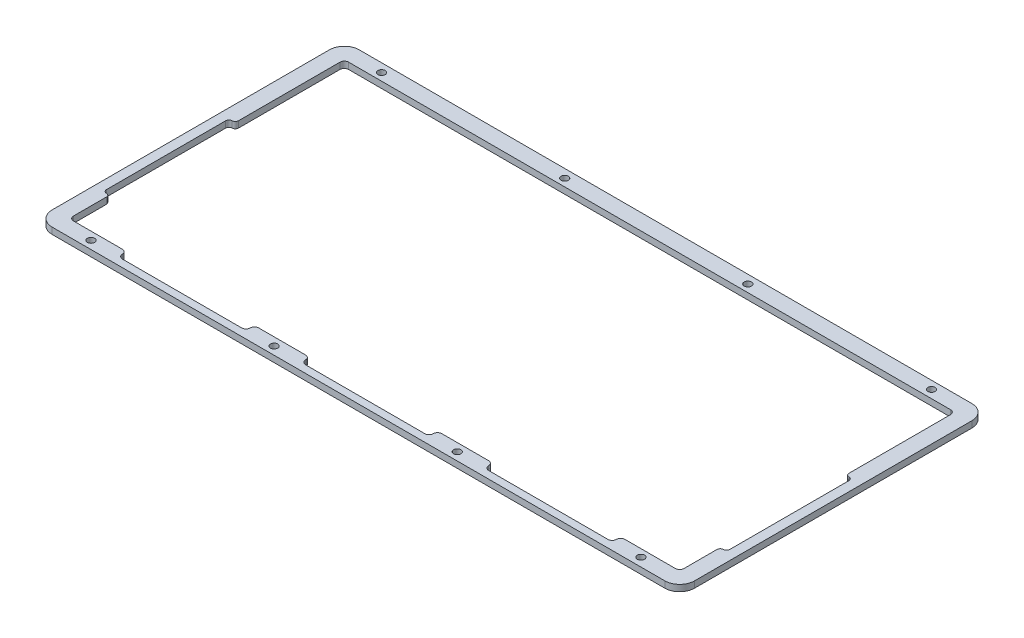
from build123d import *

# Parameters (mm, degrees)
SKETCH1_W           = 350
SKETCH1_H           = 200
BOSS_EXTRUDE1_DEPTH = 3
SKETCH2_W           = 350
SKETCH2_H           = 200
SKETCH2_R           = 1.7
CUT_EXTRUDE2_DEPTH  = 3


with BuildPart() as part:
    # Sketch1 → Boss-Extrude1 (new body)
    with BuildSketch(Plane(origin=(0, 0, 0), x_dir=(1, 0, 0), z_dir=(0, 1, 0))):
        with Locations((175, 100)):
            Rectangle(SKETCH1_W, SKETCH1_H)
    extrude(amount=BOSS_EXTRUDE1_DEPTH)

    # Sketch2 → Cut-Extrude2 (cut)
    with BuildSketch(Plane(origin=(0, 3, 0), x_dir=(1, 0, 0), z_dir=(0, 1, 0))):
        with Locations((175, 100)):
            Rectangle(SKETCH2_W, SKETCH2_H)
        with BuildLine():
            ThreePointArc((18.78172506, 5.694207131), (13.831977592, 7.744459663), (11.78172506, 12.694207131))
            Line((11.78172506, 12.694207131), (11.78172506, 142.893667131))
            ThreePointArc((11.78172506, 142.893667131), (13.831977592, 147.843414599), (18.78172506, 149.893667131))
            Line((18.78172506, 149.893667131), (306.48107506, 149.893667131))
            ThreePointArc((306.48107506, 149.893667131), (311.430822528, 147.843414599), (313.48107506, 142.893667131))
            Line((313.48107506, 142.893667131), (313.48107506, 12.694207131))
            ThreePointArc((313.48107506, 12.694207131), (311.430822528, 7.744459663), (306.48107506, 5.694207131))
            Line((306.48107506, 5.694207131), (18.78172506, 5.694207131))
        make_face(mode=Mode.SUBTRACT)
        with Locations(Location((119.28172506, 145.893667131, 0), (0, 0, 270))):
            Circle(SKETCH2_R)
        with Locations(Location((33.28172506, 145.893667131, 0), (0, 0, 270))):
            Circle(SKETCH2_R)
        with Locations(Location((205.28172506, 145.893667131, 0), (0, 0, 270))):
            Circle(SKETCH2_R)
        with Locations(Location((291.28172506, 146.143667131, 0), (0, 0, 270))):
            Circle(SKETCH2_R)
        with Locations(Location((119.28172506, 9.444207131, 0), (0, 0, 270))):
            Circle(SKETCH2_R)
        with Locations(Location((33.28172506, 9.444207131, 0), (0, 0, 270))):
            Circle(SKETCH2_R)
        with Locations(Location((205.28172506, 9.444207131, 0), (0, 0, 270))):
            Circle(SKETCH2_R)
        with Locations(Location((291.28172506, 9.694207131, 0), (0, 0, 270))):
            Circle(SKETCH2_R)
        with BuildLine():
            ThreePointArc((46.28172506, 11.194207131), (46.867511498, 9.779993569), (48.28172506, 9.194207131))
            Line((48.28172506, 9.194207131), (104.28172506, 9.194207131))
            ThreePointArc((104.28172506, 9.194207131), (105.695938623, 9.779993569), (106.28172506, 11.194207131))
            ThreePointArc((106.28172506, 11.194207131), (106.867511498, 12.608420694), (108.28172506, 13.194207131))
            Line((108.28172506, 13.194207131), (130.28172506, 13.194207131))
            ThreePointArc((130.28172506, 13.194207131), (131.695938623, 12.608420694), (132.28172506, 11.194207131))
            ThreePointArc((132.28172506, 11.194207131), (132.867511498, 9.779993569), (134.28172506, 9.194207131))
            Line((134.28172506, 9.194207131), (190.28172506, 9.194207131))
            ThreePointArc((190.28172506, 9.194207131), (191.695938623, 9.779993569), (192.28172506, 11.194207131))
            ThreePointArc((192.28172506, 11.194207131), (192.867511498, 12.608420694), (194.28172506, 13.194207131))
            Line((194.28172506, 13.194207131), (216.28172506, 13.194207131))
            ThreePointArc((216.28172506, 13.194207131), (217.695938623, 12.608420694), (218.28172506, 11.194207131))
            ThreePointArc((218.28172506, 11.194207131), (218.867511498, 9.779993569), (220.28172506, 9.194207131))
            Line((220.28172506, 9.194207131), (276.28172506, 9.194207131))
            ThreePointArc((276.28172506, 9.194207131), (277.695938623, 9.779993569), (278.28172506, 11.194207131))
            ThreePointArc((278.28172506, 11.194207131), (278.867511498, 12.608420694), (280.28172506, 13.194207131))
            Line((280.28172506, 13.194207131), (303.98107506, 13.194207131))
            ThreePointArc((303.98107506, 13.194207131), (305.395288623, 13.779993569), (305.98107506, 15.194207131))
            Line((305.98107506, 15.194207131), (305.98107506, 30.694207131))
            ThreePointArc((305.98107506, 30.694207131), (306.420414888, 31.754867303), (307.48107506, 32.194207131))
            ThreePointArc((307.48107506, 32.194207131), (308.541735232, 32.633546959), (308.98107506, 33.694207131))
            Line((308.98107506, 33.694207131), (308.98107506, 89.694207131))
            ThreePointArc((308.98107506, 89.694207131), (308.541735232, 90.754867303), (307.48107506, 91.194207131))
            ThreePointArc((307.48107506, 91.194207131), (306.420414888, 91.633546959), (305.98107506, 92.694207131))
            Line((305.98107506, 92.694207131), (305.98107506, 140.393667131))
            ThreePointArc((305.98107506, 140.393667131), (305.395288623, 141.807880694), (303.98107506, 142.393667131))
            Line((303.98107506, 142.393667131), (21.28172506, 142.393667131))
            ThreePointArc((21.28172506, 142.393667131), (19.867511498, 141.807880694), (19.28172506, 140.393667131))
            Line((19.28172506, 140.393667131), (19.28172506, 92.694207131))
            ThreePointArc((19.28172506, 92.694207131), (18.842385232, 91.633546959), (17.78172506, 91.194207131))
            ThreePointArc((17.78172506, 91.194207131), (16.721064888, 90.754867303), (16.28172506, 89.694207131))
            Line((16.28172506, 89.694207131), (16.28172506, 33.694207131))
            ThreePointArc((16.28172506, 33.694207131), (16.721064888, 32.633546959), (17.78172506, 32.194207131))
            ThreePointArc((17.78172506, 32.194207131), (18.842385232, 31.754867303), (19.28172506, 30.694207131))
            Line((19.28172506, 30.694207131), (19.28172506, 15.194207131))
            ThreePointArc((19.28172506, 15.194207131), (19.867511498, 13.779993569), (21.28172506, 13.194207131))
            Line((21.28172506, 13.194207131), (44.28172506, 13.194207131))
            ThreePointArc((44.28172506, 13.194207131), (45.695938623, 12.608420694), (46.28172506, 11.194207131))
        make_face()
    extrude(amount=-CUT_EXTRUDE2_DEPTH, mode=Mode.SUBTRACT)


solid = part.part
